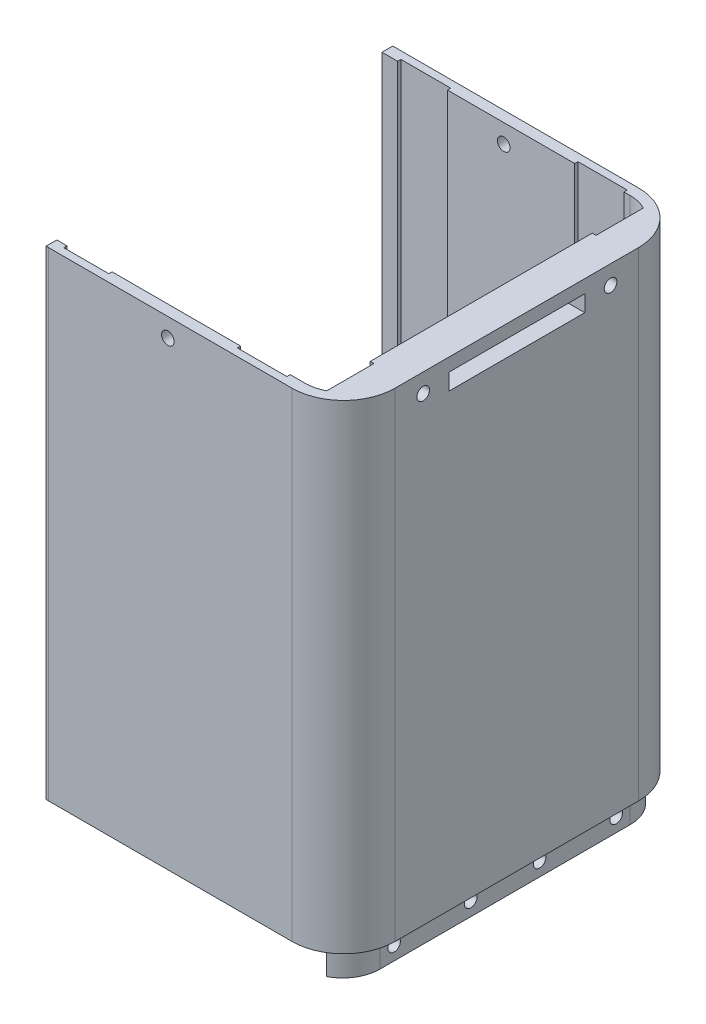
from build123d import *

# Parameters (mm, degrees)
BOSS_EXTRUDE1_DEPTH = 120
BOSS_EXTRUDE2_DEPTH = 120
SKETCH4_W           = 0.8
SKETCH4_H           = 47.4
BOSS_EXTRUDE3_DEPTH = 120
BOSS_EXTRUDE4_DEPTH = 6
SKETCH6_W           = 3.197214061
SKETCH6_H           = 10
SKETCH6_W_2         = 2.544721395
CUT_EXTRUDE1_DEPTH  = 90
SKETCH7_W           = 18.489641695
SKETCH7_H           = 120.194280457
CUT_EXTRUDE2_DEPTH  = 140
SKETCH9_W           = 8
SKETCH9_H           = 33.33003075
CUT_EXTRUDE3_DEPTH  = 4
SKETCH10_R          = 1.35
CUT_EXTRUDE4_DEPTH  = 11
SKETCH11_R          = 1.35
CUT_EXTRUDE5_DEPTH  = 11
SKETCH12_W          = 29
SKETCH12_H          = 3.5
CUT_EXTRUDE6_DEPTH  = 10
SKETCH13_W          = 93.224255338
SKETCH13_H          = 23.971951373
CUT_EXTRUDE7_DEPTH  = 103
SKETCH14_W          = 38.705642401
SKETCH14_H          = 10
CUT_EXTRUDE8_DEPTH  = 2.5
SKETCH15_R          = 1.35
CUT_EXTRUDE9_DEPTH  = 5
SKETCH16_R          = 1.35
CUT_EXTRUDE10_DEPTH = 88
SKETCH17_W          = 10.62518409
SKETCH17_H          = 1.204079054
SKETCH17_W_2        = 10.507821767
SKETCH17_W_3        = 9.64704318
SKETCH17_H_2        = 1.005507522
SKETCH17_W_4        = 10.576043604
SKETCH17_H_3        = 1.445279271
CUT_EXTRUDE11_DEPTH = 200


with BuildPart() as part:
    # Sketch1 → Boss-Extrude1 (new body)
    with BuildSketch(Plane(origin=(0, 0, 0), x_dir=(1, 0, 0), z_dir=(0, 1, 0))):
        with BuildLine():
            Line((-55.813088795, 29.403372847), (-55.813088795, -22.596627153))
            ThreePointArc((-55.813088795, -22.596627153), (-52.766075655, -30.195969229), (-45.313088795, -33.585257641))
            Line((-45.313088795, -33.585257641), (-45.313088795, -31.296627153))
            ThreePointArc((-45.313088795, -31.296627153), (-50.969943044, -28.953481402), (-53.313088795, -23.296627153))
            Line((-53.313088795, -23.296627153), (-53.313088795, 30.103372847))
            ThreePointArc((-53.313088795, 30.103372847), (-50.969943044, 35.760227097), (-45.313088795, 38.103372847))
            Line((-45.313088795, 38.103372847), (-45.313088795, 40.392003335))
            ThreePointArc((-45.313088795, 40.392003335), (-52.766075655, 37.002714924), (-55.813088795, 29.403372847))
        make_face()
        with BuildLine():
            Line((-45.313088795, -31.296627153), (-45.313088795, -33.585257641))
            ThreePointArc((-45.313088795, -33.585257641), (-45.063153419, -33.593784407), (-44.813088795, -33.596627153))
            Line((-44.813088795, -33.596627153), (7.186911205, -33.596627153))
            ThreePointArc((7.186911205, -33.596627153), (14.965085798, -30.374801746), (18.186911205, -22.596627153))
            Line((18.186911205, -22.596627153), (18.186911205, 29.403372847))
            ThreePointArc((18.186911205, 29.403372847), (14.965085798, 37.18154744), (7.186911205, 40.403372847))
            Line((7.186911205, 40.403372847), (-45.313088795, 40.403372847))
            Line((-45.313088795, 40.403372847), (-45.313088795, 40.392003335))
            Line((-45.313088795, 40.392003335), (-45.313088795, 38.103372847))
            Line((-45.313088795, 38.103372847), (7.686911205, 38.103372847))
            ThreePointArc((7.686911205, 38.103372847), (13.343765455, 35.760227097), (15.686911205, 30.103372847))
            Line((15.686911205, 30.103372847), (15.686911205, -23.296627153))
            ThreePointArc((15.686911205, -23.296627153), (13.343765455, -28.953481402), (7.686911205, -31.296627153))
            Line((7.686911205, -31.296627153), (-45.313088795, -31.296627153))
        make_face()
    extrude(amount=BOSS_EXTRUDE1_DEPTH)

    # Sketch3 → Boss-Extrude2 (add)
    with BuildSketch(Plane.XZ):
        Polygon((-49.013088795, 31.972735522), (-49.013088795, -37.623215713), (-53.336517426, -34.913867104), (-55.11106611, -29.984565206), (-55.11106611, -26.811210851), (-55.11106611, 25.452378342), (-53.652842224, 27.779331351), (-52.073193111, 30.226675048), align=None)
        Polygon((11.386911205, 31.972735522), (11.386911205, -38.487790626), (13.269736219, -37.809973621), (16.737085445, -32.276969537), (16.568342629, -31.170966754), (16.568342629, 24.789777041), (15.03852436, 28.997230807), align=None)
    extrude(amount=-BOSS_EXTRUDE2_DEPTH)

    # Sketch4 → Boss-Extrude3 (add)
    with BuildSketch(Plane.XZ):
        with Locations((10.986911205, -3.403372847)):
            Rectangle(SKETCH4_W, SKETCH4_H)
        with Locations((-48.613088795, -3.403372847)):
            Rectangle(SKETCH4_W, SKETCH4_H)
    extrude(amount=-BOSS_EXTRUDE3_DEPTH)

    # Sketch5 → Boss-Extrude4 (add)
    with BuildSketch(Plane.XZ):
        with BuildLine():
            ThreePointArc((-49.013088795, 30.389581403), (-52.154141346, 27.443915423), (-53.313088795, 23.296627153))
            Line((-53.313088795, 23.296627153), (-53.313088795, -30.103372847))
            ThreePointArc((-53.313088795, -30.103372847), (-52.154141346, -34.250661118), (-49.013088795, -37.196327098))
            Line((-49.013088795, -37.196327098), (-49.013088795, -27.103372847))
            Line((-49.013088795, -27.103372847), (-48.213088795, -27.103372847))
            Line((-48.213088795, -27.103372847), (-48.213088795, 20.296627153))
            Line((-48.213088795, 20.296627153), (-49.013088795, 20.296627153))
            Line((-49.013088795, 20.296627153), (-49.013088795, 30.389581403))
        make_face()
        with BuildLine():
            ThreePointArc((11.386911205, -37.196327098), (14.527963756, -34.250661118), (15.686911205, -30.103372847))
            Line((15.686911205, -30.103372847), (15.686911205, 23.296627153))
            ThreePointArc((15.686911205, 23.296627153), (14.527963756, 27.443915423), (11.386911205, 30.389581403))
            Line((11.386911205, 30.389581403), (11.386911205, 20.296627153))
            Line((11.386911205, 20.296627153), (10.586911205, 20.296627153))
            Line((10.586911205, 20.296627153), (10.586911205, -27.103372847))
            Line((10.586911205, -27.103372847), (11.386911205, -27.103372847))
            Line((11.386911205, -27.103372847), (11.386911205, -37.196327098))
        make_face()
    extrude(amount=BOSS_EXTRUDE4_DEPTH)

    # Sketch6 → Cut-Extrude1 (cut)
    with BuildSketch(Plane.XZ.offset(6)):
        with Locations((-49.114481764, 12.296627153)):
            Rectangle(SKETCH6_W, SKETCH6_H)
        with Locations((-49.440728097, -19.103372847)):
            Rectangle(SKETCH6_W_2, SKETCH6_H)
        with Locations((11.814550508, -19.103372847)):
            Rectangle(SKETCH6_W_2, SKETCH6_H)
        with Locations((11.488304175, 12.296627153)):
            Rectangle(SKETCH6_W, SKETCH6_H)
    extrude(amount=-CUT_EXTRUDE1_DEPTH, mode=Mode.SUBTRACT)

    # Sketch7 → Cut-Extrude2 (cut)
    with BuildSketch(Plane.XZ.offset(6)):
        with Locations((-54.557909643, -9.755963426)):
            Rectangle(SKETCH7_W, SKETCH7_H)
    extrude(amount=-CUT_EXTRUDE2_DEPTH, mode=Mode.SUBTRACT)

    # Sketch9 → Cut-Extrude3 (cut)
    with BuildSketch(Plane.ZY.offset(-10.586911205)):
        with Locations((-3.403372847, 2.334984625)):
            Rectangle(SKETCH9_W, SKETCH9_H)
    extrude(amount=-CUT_EXTRUDE3_DEPTH, mode=Mode.SUBTRACT)

    # Sketch10 → Cut-Extrude4 (cut)
    with BuildSketch(Plane.ZY.offset(-10.586911205)):
        with Locations((-10.753372847, -3)):
            Circle(SKETCH10_R)
        with Locations((3.946627153, -3)):
            Circle(SKETCH10_R)
    extrude(amount=-CUT_EXTRUDE4_DEPTH, mode=Mode.SUBTRACT)

    # Sketch11 → Cut-Extrude5 (cut)
    with BuildSketch(Plane.ZY.offset(-10.586911205)):
        with Locations((20.296627153, -3)):
            Circle(SKETCH11_R)
        with Locations((-27.103372847, -3)):
            Circle(SKETCH11_R)
    extrude(amount=-CUT_EXTRUDE5_DEPTH, mode=Mode.SUBTRACT)

    # Sketch12 → Cut-Extrude6 (cut)
    with BuildSketch(Plane(origin=(18.186911205, 0, 0), x_dir=(0, 0, -1), z_dir=(1, 0, 0))):
        with Locations((3.403372847, 97.75)):
            Rectangle(SKETCH12_W, SKETCH12_H)
    extrude(amount=-CUT_EXTRUDE6_DEPTH, mode=Mode.SUBTRACT)

    # Sketch13 → Cut-Extrude7 (cut)
    with BuildSketch(Plane(origin=(18.186911205, 0, 0), x_dir=(0, 0, -1), z_dir=(1, 0, 0))):
        with Locations((2.372000063, 114.285975687)):
            Rectangle(SKETCH13_W, SKETCH13_H)
    extrude(amount=-CUT_EXTRUDE7_DEPTH, mode=Mode.SUBTRACT)

    # Sketch14 → Cut-Extrude8 (cut)
    with BuildSketch(Plane.ZY.offset(-10.586911205)):
        with Locations((-2.056194048, 79)):
            Rectangle(SKETCH14_W, SKETCH14_H)
    extrude(amount=-CUT_EXTRUDE8_DEPTH, mode=Mode.SUBTRACT)

    # Sketch15 → Cut-Extrude9 (cut)
    with BuildSketch(Plane(origin=(18.186911205, 0, 0), x_dir=(0, 0, -1), z_dir=(1, 0, 0))):
        with Locations((23.403372847, 98.3)):
            Circle(SKETCH15_R)
        with Locations((-16.596627153, 98.3)):
            Circle(SKETCH15_R)
    extrude(amount=-CUT_EXTRUDE9_DEPTH, mode=Mode.SUBTRACT)

    # Sketch16 → Cut-Extrude10 (cut)
    with BuildSketch(Plane.XY.offset(33.596627153)):
        with Locations((-19.313088795, 98.3)):
            Circle(SKETCH16_R)
    extrude(amount=-CUT_EXTRUDE10_DEPTH, mode=Mode.SUBTRACT)

    # Sketch17 → Cut-Extrude11 (cut)
    with BuildSketch(Plane(origin=(0, 102.3, 0), x_dir=(1, 0, 0), z_dir=(0, 1, 0))):
        with Locations((-36.645164777, 38.20133332)):
            Rectangle(SKETCH17_W, SKETCH17_H)
        with Locations((1.096553781, 38.20133332)):
            Rectangle(SKETCH17_W_2, SKETCH17_H)
        with Locations((-38.338294946, -31.493873392)):
            Rectangle(SKETCH17_W_3, SKETCH17_H_2)
        with Locations((-0.803500168, -31.273987518)):
            Rectangle(SKETCH17_W_4, SKETCH17_H_3)
    extrude(amount=-CUT_EXTRUDE11_DEPTH, mode=Mode.SUBTRACT)


solid = part.part
